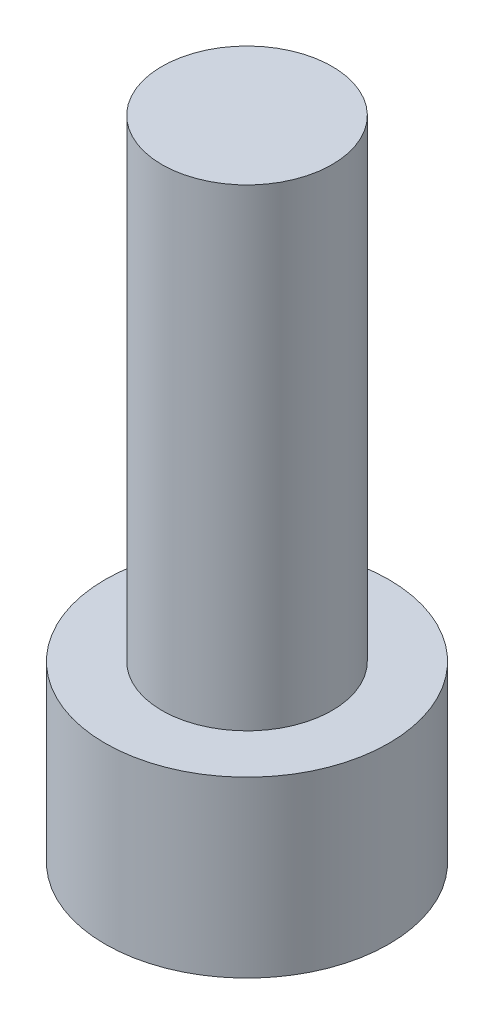
from build123d import *

# Parameters (mm, degrees)
SKETCH1_R           = 2.8575
BOSS_EXTRUDE1_DEPTH = 3.5052
CUT_EXTRUDE1_DEPTH  = 1.9558
SKETCH3_R           = 1.7145
BOSS_EXTRUDE2_DEPTH = 9.525


with BuildPart() as part:
    # Sketch1 → Boss-Extrude1 (new body)
    with BuildSketch(Plane(origin=(0, 0, 0), x_dir=(1, 0, 0), z_dir=(0, 1, 0))):
        Circle(SKETCH1_R)
    extrude(amount=BOSS_EXTRUDE1_DEPTH)

    # Sketch2 → Cut-Extrude1 (cut)
    with BuildSketch(Plane.XZ):
        Polygon((1.603951217, 0), (0.801975608, 1.3890625), (-0.801975608, 1.3890625), (-1.603951217, 0), (-0.801975608, -1.3890625), (0.801975608, -1.3890625), align=None)
    extrude(amount=-CUT_EXTRUDE1_DEPTH, mode=Mode.SUBTRACT)

    # Sketch3 → Boss-Extrude2 (add)
    with BuildSketch(Plane(origin=(0, 3.5052, 0), x_dir=(1, 0, 0), z_dir=(0, 1, 0))):
        Circle(SKETCH3_R)
    extrude(amount=BOSS_EXTRUDE2_DEPTH)


solid = part.part
